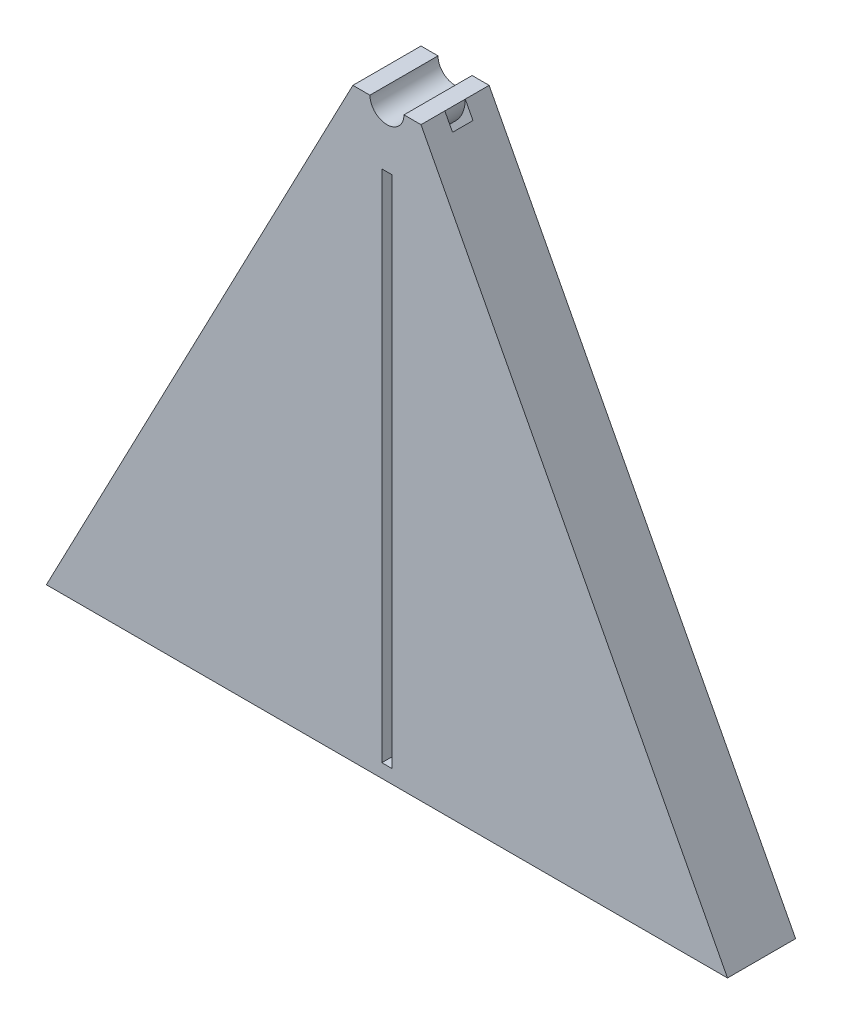
from build123d import *

# Parameters (mm, degrees)
BOSS_EXTRUDE1_DEPTH = 10
SKETCH2_R           = 6.5
SKETCH2_R_2         = 5
CUT_EXTRUDE1_DEPTH  = 6.5
BOSS_EXTRUDE2_DEPTH = 3.5
SKETCH4_W           = 1.5
SKETCH4_H           = 75.5
CUT_EXTRUDE2_DEPTH  = 11


with BuildPart() as part:
    # Sketch1 → Boss-Extrude1 (new body)
    with BuildSketch(Plane.XY):
        with BuildLine():
            Line((-50, -86), (50, -86))
            Line((50, -86), (5, 0))
            Line((5, 0), (2.5, 0))
            ThreePointArc((2.5, 0), (0, -2.5), (-2.5, 0))
            Line((-2.5, 0), (-5, 0))
            Line((-5, 0), (-50, -86))
        make_face()
    extrude(amount=BOSS_EXTRUDE1_DEPTH)

    # Sketch2 → Cut-Extrude1 (cut)
    with BuildSketch(Plane.XY.offset(10)):
        Circle(SKETCH2_R)
        Circle(SKETCH2_R_2, mode=Mode.SUBTRACT)
    extrude(amount=-CUT_EXTRUDE1_DEPTH, mode=Mode.SUBTRACT)

    # Sketch3 → Boss-Extrude2 (add)
    with BuildSketch(Plane.XY.offset(10)):
        with BuildLine():
            Line((5, 0), (6.130459134, -2.160433012))
            ThreePointArc((6.130459134, -2.160433012), (0, -6.5), (-6.130459134, -2.160433012))
            Line((-6.130459134, -2.160433012), (-5, 0))
            ThreePointArc((-5, 0), (0, -5), (5, 0))
        make_face()
    extrude(amount=-BOSS_EXTRUDE2_DEPTH)

    # Sketch4 → Cut-Extrude2 (cut, through all)
    with BuildSketch(Plane.XY.offset(10)):
        with Locations((0, -46.25)):
            Rectangle(SKETCH4_W, SKETCH4_H)
    extrude(amount=-CUT_EXTRUDE2_DEPTH, mode=Mode.SUBTRACT)


solid = part.part
